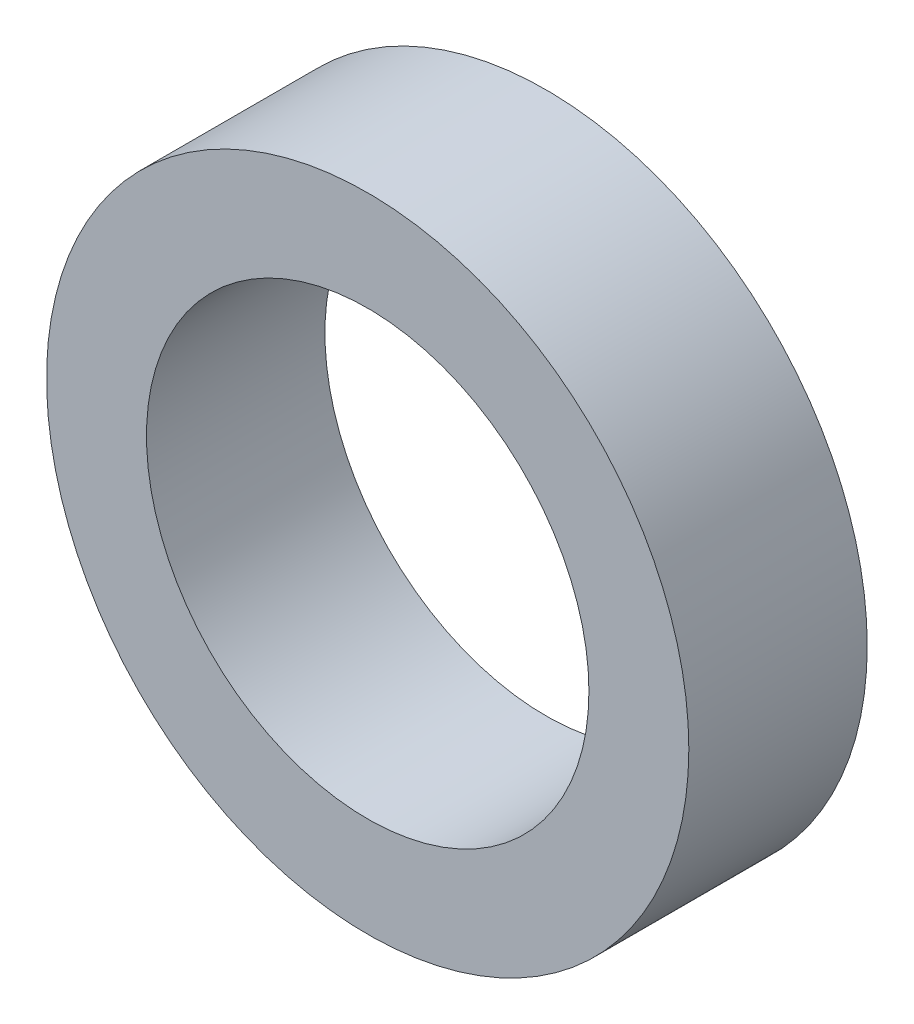
from build123d import *

# Parameters (mm, degrees)
SKETCH1_R           = 9
SKETCH1_R_2         = 6.2
BOSS_EXTRUDE1_DEPTH = 5


with BuildPart() as part:
    # Sketch1 → Boss-Extrude1 (new body)
    with BuildSketch(Plane.XY):
        Circle(SKETCH1_R)
        Circle(SKETCH1_R_2, mode=Mode.SUBTRACT)
    extrude(amount=BOSS_EXTRUDE1_DEPTH)


solid = part.part
